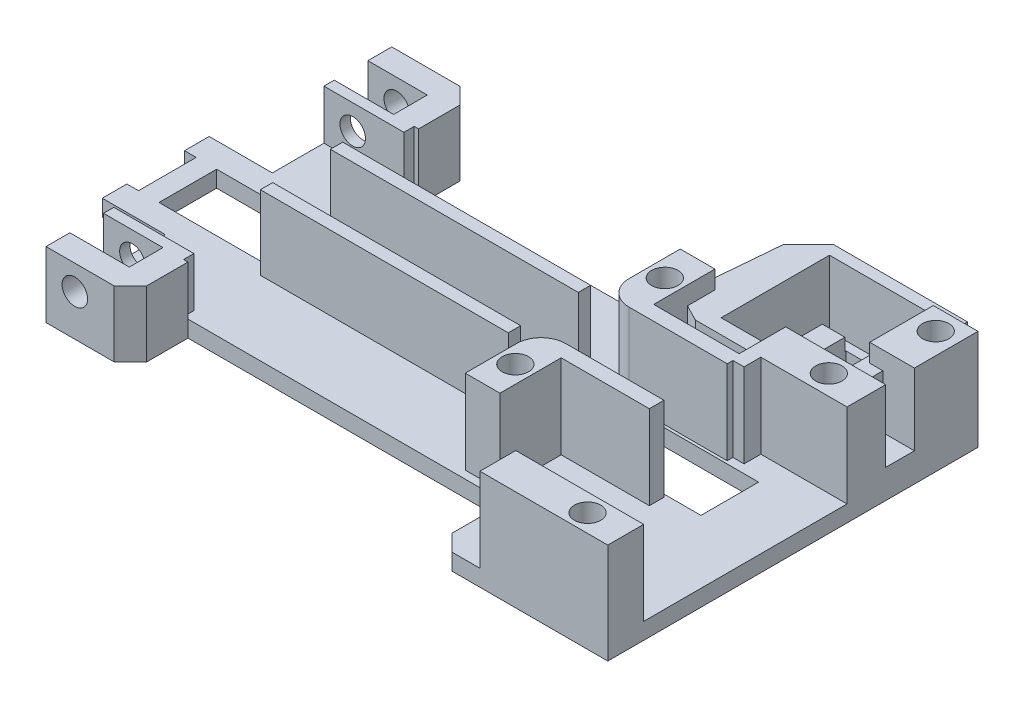
from build123d import *

# Parameters (mm, degrees)
SKETCH_1_W          = 65.796682854
SKETCH_1_H          = 7
EXTRUDE_1_DEPTH     = 1
SKETCH_1_3_W        = 65.796682854
SKETCH_1_3_H        = 7
EXTRUDE_4_DEPTH     = 1
SKETCH_2_R          = 1.6
SKETCH_2_W          = 15.527024866
SKETCH_2_H          = 4.354426868
EXTRUDE_5_DEPTH     = 10.2
SKETCH_3_W          = 11.091265895
SKETCH_3_H          = 1.250873396
EXTRUDE_6_DEPTH     = 8
EXTRUDE_7_DEPTH     = 8
SKETCH_5_R          = 1.55
CUT_EXTRUDE_1_DEPTH = 46.168181955
SKETCH_6_W          = 30.095890068
SKETCH_6_H          = 1.5
EXTRUDE_8_DEPTH     = 9
SKETCH_9_R          = 1.6
EXTRUDE_9_DEPTH     = 10.2
SKETCH_10_W         = 18.90463159
SKETCH_10_H         = 11.206527224
EXTRUDE_10_DEPTH    = 1.5
EXTRUDE_11_DEPTH    = 10
SKETCH_12_W         = 6.619618948
SKETCH_12_H         = 10.208127021
CUT_EXTRUDE_2_DEPTH = 4
SKETCH_13_W         = 5.420961308
SKETCH_13_H         = 7.723522143
EXTRUDE_12_DEPTH    = 8.7
SKETCH_14_R         = 1.6
CUT_EXTRUDE_3_DEPTH = 8
SKETCH_15_W         = 1.5
SKETCH_15_H         = 14.498100707
CUT_EXTRUDE_4_DEPTH = 9


with BuildPart() as part:
    # 草图1 → 凸台-拉伸1 (new body)
    with BuildSketch(Plane(origin=(0, 0, 0), x_dir=(1, 0, 0), z_dir=(0, 1, 0))):
        Polygon((21.783137071, 14), (-26.5, 14), (-26.5, 6.489174383), (-32.668192158, 6.489174383), (-32.668192158, 4.906407062), (-32.668192158, 3.5), (-31.253928934, 3.5), (-31.253928934, -3.5), (-32.668192158, -3.5), (-32.668192158, -4.906407062), (-32.668192158, -6.489174383), (-26.5, -6.489174383), (-26.5, -14), (21.783137071, -14), (23.783137071, -16), (23.783137071, -20.472436035), (25.783137071, -22.472436035), (44.687768661, -22.472436035), (44.687768661, -14), (44.687768661, 14), (44.687768661, 22.472436035), (39.670641652, 22.472436035), (39.670641652, 24.180906865), (37.700847745, 24.180906865), (25.783137071, 24.180906865), (23.783137071, 21.491786563), (23.783137071, 20.472436035), (23.783137071, 16), align=None)
        with Locations((4.125276897, 0)):
            Rectangle(SKETCH_1_W, SKETCH_1_H, mode=Mode.SUBTRACT)
    extrude(amount=EXTRUDE_1_DEPTH)

    # 草图1<3> → 凸台-拉伸4 (add)
    with BuildSketch(Plane(origin=(0, 0, 0), x_dir=(1, 0, 0), z_dir=(0, 1, 0))):
        Polygon((21.783137071, 14), (-26.5, 14), (-26.5, 6.489174383), (-32.668192158, 6.489174383), (-32.668192158, 4.906407062), (-32.668192158, 3.5), (-31.253928934, 3.5), (-31.253928934, -3.5), (-32.668192158, -3.5), (-32.668192158, -4.906407062), (-32.668192158, -6.489174383), (-26.5, -6.489174383), (-26.5, -14), (21.783137071, -14), (23.783137071, -16), (23.783137071, -20.472436035), (25.783137071, -22.472436035), (44.687768661, -22.472436035), (44.687768661, -14), (44.687768661, 14), (44.687768661, 22.472436035), (39.670641652, 22.472436035), (39.670641652, 24.180906865), (37.700847745, 24.180906865), (25.783137071, 24.180906865), (23.783137071, 21.491786563), (23.783137071, 20.472436035), (23.783137071, 16), align=None)
        with Locations((4.125276897, 0)):
            Rectangle(SKETCH_1_3_W, SKETCH_1_3_H, mode=Mode.SUBTRACT)
    extrude(amount=-EXTRUDE_4_DEPTH)

    # 草图2 → 凸台-拉伸5 (add)
    with BuildSketch(Plane(origin=(0, 1, 0), x_dir=(1, 0, 0), z_dir=(0, 1, 0))):
        with BuildLine():
            Line((32.873825551, -3.837422495), (20.961538439, -3.837422495))
            ThreePointArc((20.961538439, -3.837422495), (18.840218096, -4.716102152), (17.961538439, -6.837422495))
            Line((17.961538439, -6.837422495), (17.961538439, -9.071638955))
            Line((17.961538439, -9.071638955), (17.961538439, -13.050495751))
            Line((17.961538439, -13.050495751), (22.173089039, -13.050495751))
            Line((22.173089039, -13.050495751), (22.173089039, -9.071638955))
            Line((22.173089039, -9.071638955), (22.173089039, -5.615284864))
            Line((22.173089039, -5.615284864), (32.873825551, -5.615284864))
            Line((32.873825551, -5.615284864), (32.873825551, -3.837422495))
        make_face()
        with Locations((20.064403013, -9.071638955)):
            Circle(SKETCH_2_R, mode=Mode.SUBTRACT)
        Polygon((34.225317019, 6.570554911), (44.687768661, 6.570554911), (44.687768661, 11.265908811), (32.547793792, 11.265908811), (32.547793792, 4.534516494), (34.225317019, 4.534516494), align=None)
        with Locations((40.063673511, 8.987084634)):
            Circle(SKETCH_2_R, mode=Mode.SUBTRACT)
        with Locations((36.924256228, -20.295222601)):
            Rectangle(SKETCH_2_W, SKETCH_2_H)
        with Locations((40.063673511, -20.300345076)):
            Circle(SKETCH_2_R, mode=Mode.SUBTRACT)
    extrude(amount=EXTRUDE_5_DEPTH)

    # 草图3 → 凸台-拉伸6 (add)
    with BuildSketch(Plane.XZ.offset(1)):
        with Locations((-20.830181881, -13.374563302)):
            Rectangle(SKETCH_3_W, SKETCH_3_H)
        with Locations((-20.830181881, 13.374563302)):
            Rectangle(SKETCH_3_W, SKETCH_3_H)
    extrude(amount=-EXTRUDE_6_DEPTH)

    # 草图4 → 凸台-拉伸7 (add)
    with BuildSketch(Plane.XZ.offset(1)):
        Polygon((-14.752508247, -14), (-14.752508247, -19.024004183), (-16.715779154, -20.98727509), (-26.5, -20.98727509), (-26.5, -18.091791799), (-17.787107971, -18.091791799), (-17.787107971, -14), align=None)
        Polygon((-26.5, 20.98727509), (-26.5, 18.091791799), (-17.787107971, 18.091791799), (-17.787107971, 14), (-14.752508247, 14), (-14.752508247, 19.024004183), (-16.715779154, 20.98727509), align=None)
    extrude(amount=-EXTRUDE_7_DEPTH)

    # 草图5 → 切除-拉伸1 (cut, through all)
    with BuildSketch(Plane.XY.offset(20.98727509)):
        with Locations((-21.5, 4)):
            Circle(SKETCH_5_R)
    extrude(amount=-CUT_EXTRUDE_1_DEPTH, mode=Mode.SUBTRACT)

    # 草图6 → 凸台-拉伸8 (add)
    with BuildSketch(Plane(origin=(0, 1, 0), x_dir=(1, 0, 0), z_dir=(0, 1, 0))):
        with Locations((0.084132632, 4.25)):
            Rectangle(SKETCH_6_W, SKETCH_6_H)
        with Locations((0.084132632, -4.25)):
            Rectangle(SKETCH_6_W, SKETCH_6_H)
    extrude(amount=EXTRUDE_8_DEPTH)

    # 草图9 → 凸台-拉伸9 (add)
    with BuildSketch(Plane(origin=(0, 1, 0), x_dir=(1, 0, 0), z_dir=(0, 1, 0))):
        with BuildLine():
            Line((17.961538439, 6.837422495), (17.961538439, 13.050495751))
            Line((17.961538439, 13.050495751), (22.173089039, 13.050495751))
            Line((22.173089039, 13.050495751), (22.173089039, 5.615284864))
            Line((22.173089039, 5.615284864), (32.873825551, 5.615284864))
            Line((32.873825551, 5.615284864), (32.873825551, 3.837422495))
            Line((32.873825551, 3.837422495), (20.961538439, 3.837422495))
            ThreePointArc((20.961538439, 3.837422495), (18.840218096, 4.716102152), (17.961538439, 6.837422495))
        make_face()
        with Locations((20.064403013, 9.071638955)):
            Circle(SKETCH_9_R, mode=Mode.SUBTRACT)
    extrude(amount=EXTRUDE_9_DEPTH)

    # 草图10 → 凸台-拉伸10 (add)
    with BuildSketch(Plane(origin=(0, 1, 0), x_dir=(1, 0, 0), z_dir=(0, 1, 0))):
        with Locations((35.235452866, 16.869172423)):
            Rectangle(SKETCH_10_W, SKETCH_10_H)
    extrude(amount=EXTRUDE_10_DEPTH)

    # 草图11 → 凸台-拉伸11 (add)
    with BuildSketch(Plane.XZ.offset(1)):
        Polygon((32.547793792, -10.505295771), (25.467909356, -10.505295771), (25.467909356, -23.65934808), (38.4386145, -23.65934808), (38.4386145, -11.265908811), (40.863684521, -11.265908811), (40.863684521, -25.029182917), (24.636389842, -25.029182917), (21.547173342, -21.939966418), (20.550925149, -10.56366418), (24.129557088, -8.707277705), (32.547793792, -8.707277705), align=None)
    extrude(amount=-EXTRUDE_11_DEPTH)

    # 草图12 → 切除-拉伸2 (cut)
    with BuildSketch(Plane.XZ.offset(1)):
        with Locations((31.84517955, -17.496385448)):
            Rectangle(SKETCH_12_W, SKETCH_12_H)
    extrude(amount=-CUT_EXTRUDE_2_DEPTH, mode=Mode.SUBTRACT)

    # 草图13 → 凸台-拉伸12 (add)
    with BuildSketch(Plane(origin=(0, 2.5, 0), x_dir=(1, 0, 0), z_dir=(0, 1, 0))):
        with Locations((41.977288007, 18.610674964)):
            Rectangle(SKETCH_13_W, SKETCH_13_H)
    extrude(amount=EXTRUDE_12_DEPTH)

    # 草图14 → 切除-拉伸3 (cut)
    with BuildSketch(Plane(origin=(0, 11.2, 0), x_dir=(1, 0, 0), z_dir=(0, 1, 0))):
        with Locations((42.105027807, 19.921488723)):
            Circle(SKETCH_14_R)
    extrude(amount=-CUT_EXTRUDE_3_DEPTH, mode=Mode.SUBTRACT)

    # 草图15 → 切除-拉伸4 (cut, through all)
    with BuildSketch(Plane(origin=(0, 7, 0), x_dir=(1, 0, 0), z_dir=(0, 1, 0))):
        with Locations((-25.75, 13.738224737)):
            Rectangle(SKETCH_15_W, SKETCH_15_H)
        with Locations((-25.75, -13.738224737)):
            Rectangle(SKETCH_15_W, SKETCH_15_H)
    extrude(amount=-CUT_EXTRUDE_4_DEPTH, mode=Mode.SUBTRACT)


solid = part.part
